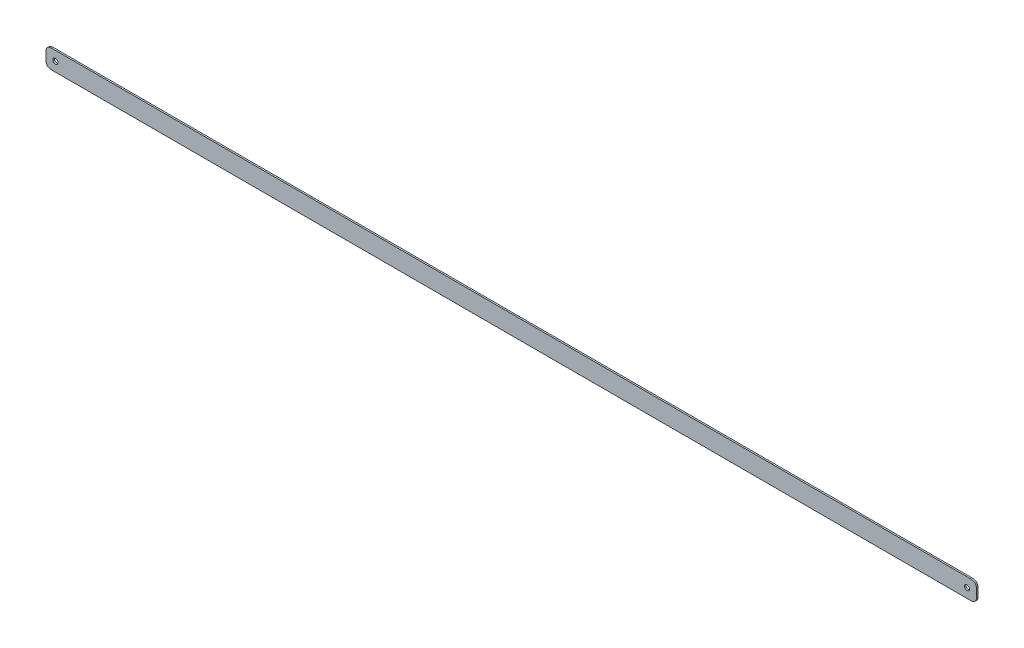
from build123d import *

# Parameters (mm, degrees)
SKETCH1_R           = 2.54
BOSS_EXTRUDE1_DEPTH = 1.5875


with BuildPart() as part:
    # Sketch1 → Boss-Extrude1 (new body)
    with BuildSketch(Plane.XY):
        with BuildLine():
            Line((-4.445, 9.525), (929.119441224, 9.525))
            ThreePointArc((929.119441224, 9.525), (932.711543672, 8.037102448), (934.199441224, 4.445))
            Line((934.199441224, 4.445), (934.199441224, -4.445))
            ThreePointArc((934.199441224, -4.445), (932.711543672, -8.037102448), (929.119441224, -9.525))
            Line((929.119441224, -9.525), (-4.445, -9.525))
            ThreePointArc((-4.445, -9.525), (-8.037102448, -8.037102448), (-9.525, -4.445))
            Line((-9.525, -4.445), (-9.525, 4.445))
            ThreePointArc((-9.525, 4.445), (-8.037102448, 8.037102448), (-4.445, 9.525))
        make_face()
        Circle(SKETCH1_R, mode=Mode.SUBTRACT)
        with Locations((924.674441224, 0)):
            Circle(SKETCH1_R, mode=Mode.SUBTRACT)
    extrude(amount=BOSS_EXTRUDE1_DEPTH)


solid = part.part
